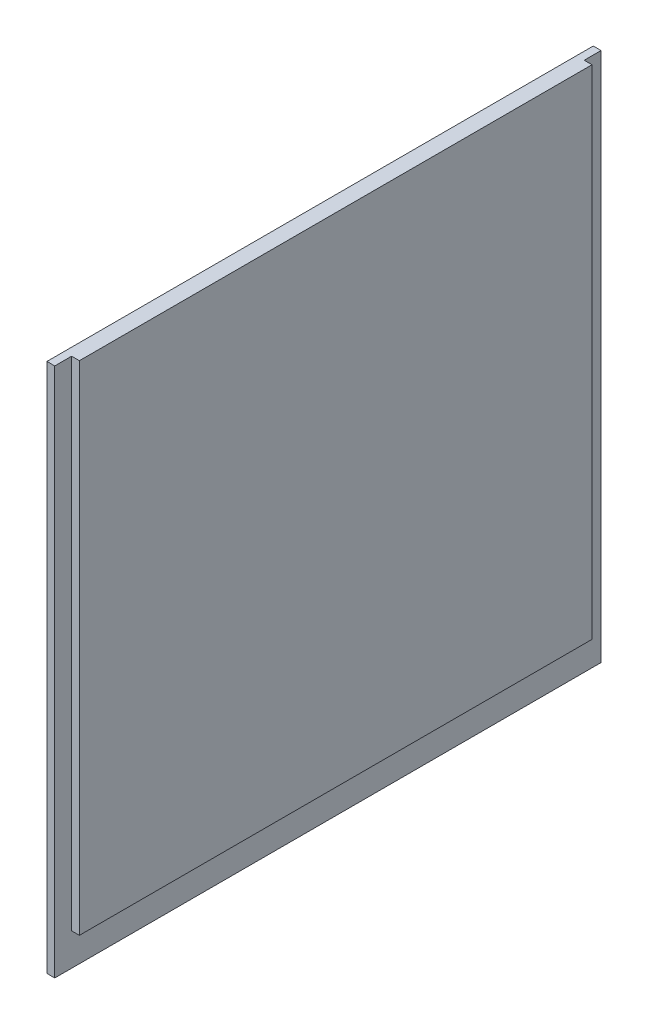
from build123d import *

# Parameters (mm, degrees)
SKETCH1_W           = 111.252
SKETCH1_H           = 107.95
BOSS_EXTRUDE1_DEPTH = 1.5875
SKETCH2_W           = 104.394
SKETCH2_H           = 101.346
BOSS_EXTRUDE2_DEPTH = 1.5875


with BuildPart() as part:
    # Sketch1 → Boss-Extrude1 (new body)
    with BuildSketch(Plane(origin=(0, 0, 0), x_dir=(0, 0, -1), z_dir=(1, 0, 0))):
        with Locations((55.626, 53.975)):
            Rectangle(SKETCH1_W, SKETCH1_H)
    extrude(amount=BOSS_EXTRUDE1_DEPTH)

    # Sketch2 → Boss-Extrude2 (add)
    with BuildSketch(Plane(origin=(1.5875, 0, 0), x_dir=(0, 0, -1), z_dir=(1, 0, 0))):
        with Locations((55.626, 57.277)):
            Rectangle(SKETCH2_W, SKETCH2_H)
    extrude(amount=BOSS_EXTRUDE2_DEPTH)


solid = part.part
